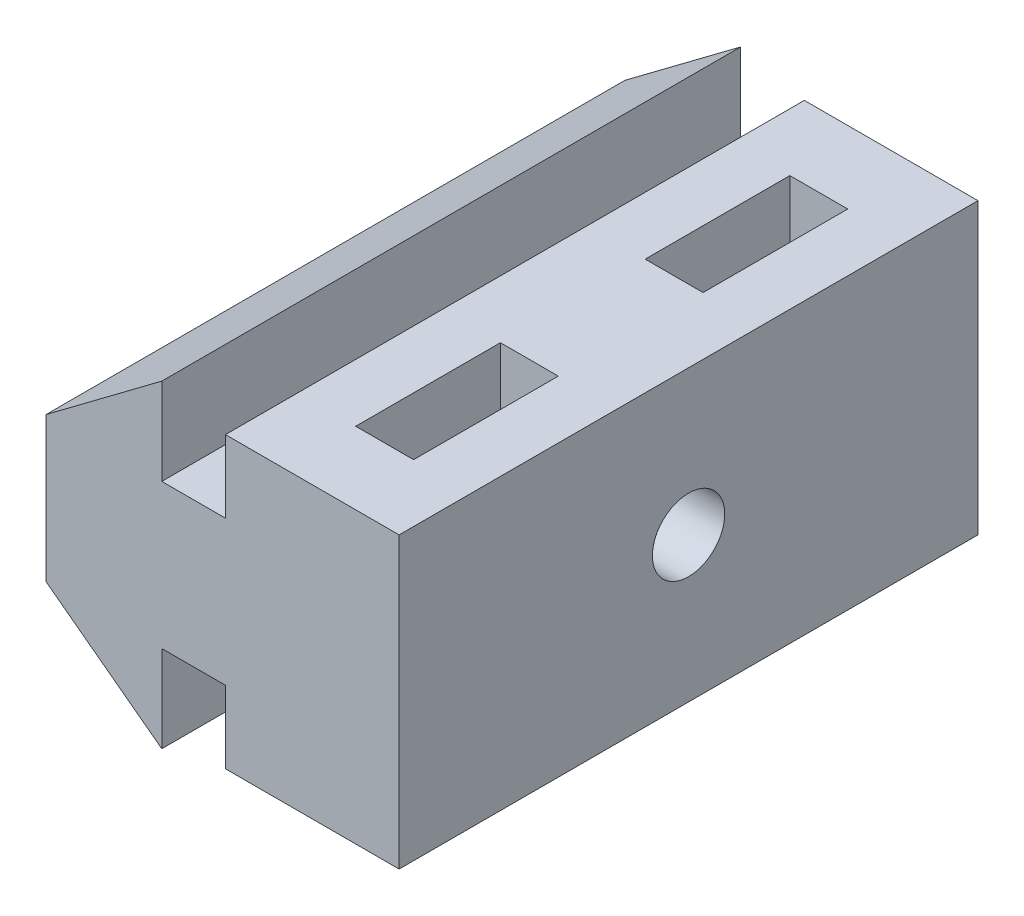
from build123d import *

# Parameters (mm, degrees)
BOSS_EXTRU_1_DEPTH      = 20
ESQUISSE1_R             = 1.25
ENL_V_MAT_EXTRU_1_DEPTH = 13.2
ESQUISSE2_W             = 2
ESQUISSE2_H             = 5
ENL_V_MAT_EXTRU_2_DEPTH = 11.5


with BuildPart() as part:
    # ProfileRainureEsquisse → Boss.-Extru.1 (new body)
    with BuildSketch(Plane.XY):
        Polygon((0, 0), (0, 5), (4, 8), (4, 5), (6.2, 5), (6.2, 7.5), (12.2, 7.5), (12.2, -2.5), (6.2, -2.5), (6.2, 0), (4, 0), (4, -3), align=None)
    extrude(amount=BOSS_EXTRU_1_DEPTH)

    # Esquisse1 → Enlèv. mat.-Extru.1 (cut, through all)
    with BuildSketch(Plane(origin=(12.2, 0, 0), x_dir=(0, 0, -1), z_dir=(1, 0, 0))):
        with Locations((-10, 2.5)):
            Circle(ESQUISSE1_R)
    extrude(amount=-ENL_V_MAT_EXTRU_1_DEPTH, mode=Mode.SUBTRACT)

    # Esquisse2 → Enlèv. mat.-Extru.2 (cut, through all)
    with BuildSketch(Plane(origin=(0, 7.5, 0), x_dir=(1, 0, 0), z_dir=(0, 1, 0))):
        with Locations((9.2, -15)):
            Rectangle(ESQUISSE2_W, ESQUISSE2_H)
        with Locations((9.2, -5)):
            Rectangle(ESQUISSE2_W, ESQUISSE2_H)
    extrude(amount=-ENL_V_MAT_EXTRU_2_DEPTH, mode=Mode.SUBTRACT)


solid = part.part
